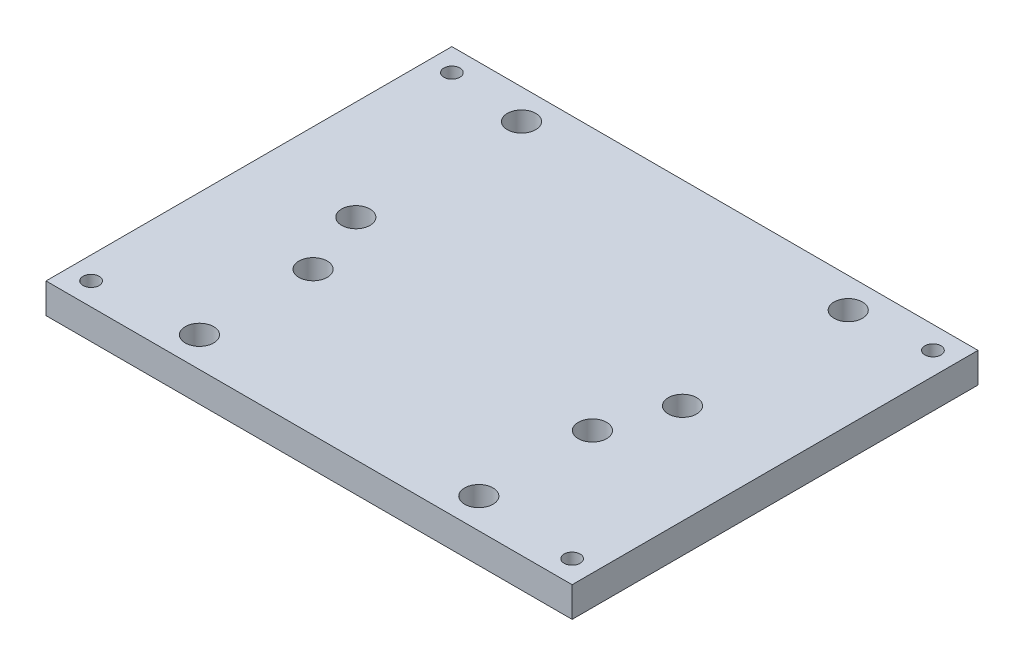
from build123d import *

# Parameters (mm, degrees)
SKETCH1_W            = 111.125
SKETCH1_H            = 85.725
BOSS_EXTRUDE1_DEPTH  = 6.35
M3_CLEARANCE_HOLE1_D = 3.4
SKETCH3_R            = 3
CUT_EXTRUDE1_DEPTH   = 7.35


with BuildPart() as part:
    # Sketch1 → Boss-Extrude1 (new body)
    with BuildSketch(Plane(origin=(0, 0, 0), x_dir=(1, 0, 0), z_dir=(0, 1, 0))):
        Rectangle(SKETCH1_W, SKETCH1_H)
    extrude(amount=BOSS_EXTRUDE1_DEPTH)

    # M3 Clearance Hole1 (through all)
    with Locations(Plane(origin=(-50.8, 0, 38.1), x_dir=(0, 0, -1), z_dir=(0, -1, 0))):
        with Locations((0, 0), (0, 101.6), (76.2, 0), (76.2, 101.6)):
            Hole(M3_CLEARANCE_HOLE1_D / 2)

    # Sketch3 → Cut-Extrude1 (cut, through all)
    with BuildSketch(Plane(origin=(0, 6.35, 0), x_dir=(1, 0, 0), z_dir=(0, 1, 0))):
        with Locations((-34.5, 36.5125)):
            Circle(SKETCH3_R)
        with Locations((34.5, 36.5125)):
            Circle(SKETCH3_R)
        with Locations((34.5, 1.5125)):
            Circle(SKETCH3_R)
        with Locations((-34.5, 1.5125)):
            Circle(SKETCH3_R)
        with Locations((-29.5, -12.5125)):
            Circle(SKETCH3_R)
        with Locations((-29.5, -36.5125)):
            Circle(SKETCH3_R)
        with Locations((29.5, -36.5125)):
            Circle(SKETCH3_R)
        with Locations((29.5, -12.5125)):
            Circle(SKETCH3_R)
    extrude(amount=-CUT_EXTRUDE1_DEPTH, mode=Mode.SUBTRACT)


solid = part.part
